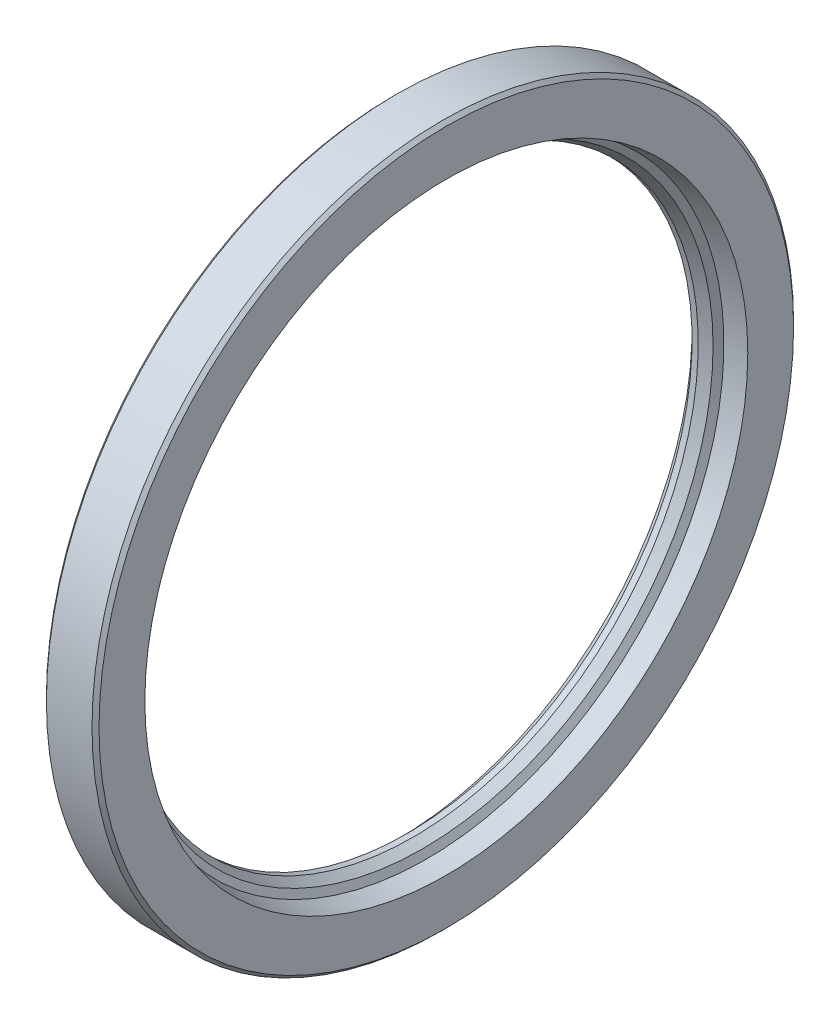
from build123d import *

# Parameters (mm, degrees)
EQ1_R = 1.40625


with BuildPart() as part:
    # eq → KR (revolve)
    with BuildSketch(Plane.XY):
        with BuildLine():
            Line((-6, 77.1875), (-6, 79.2))
            Line((-6, 79.2), (-5.2, 80))
            Line((-5.2, 80), (5.2, 80))
            Line((5.2, 80), (6, 79.2))
            Line((6, 79.2), (6, 68.75))
            Line((6, 68.75), (1.5, 67.805181388))
            Line((1.5, 67.805181388), (0.594079156, 66.236080458))
            Line((0.594079156, 66.236080458), (-1.546875, 65))
            Line((-1.546875, 65), (-2.953125, 65))
            Line((-2.953125, 65), (-5.0625, 67.109375))
            Line((-5.0625, 67.109375), (-5.0625, 69.453125))
            Line((-5.0625, 69.453125), (-3.65625, 69.453125))
            Line((-3.65625, 69.453125), (-3.65625, 68.75))
            ThreePointArc((-3.65625, 68.75), (-2.25, 67.34375), (-0.84375, 68.75))
            Line((-0.84375, 68.75), (0.375, 69.005888374))
            Line((0.375, 69.005888374), (0.375, 74.883431642))
            ThreePointArc((0.375, 74.883431642), (0.045999998, 75.787351718), (-0.78705725, 76.268317544))
            Line((-0.78705725, 76.268317544), (-6, 77.1875))
        make_face()
    revolve(axis=Axis((-6, 0, 0), (1, 0, 0)))


with BuildPart() as body_2:
    # eq1 → PR (revolve)
    with BuildSketch(Plane.XY):
        with Locations((-2.25, 68.75)):
            Circle(EQ1_R)
    revolve(axis=Axis((-6, 0, 0), (1, 0, 0)))


solid = Compound([part.part, body_2.part])
